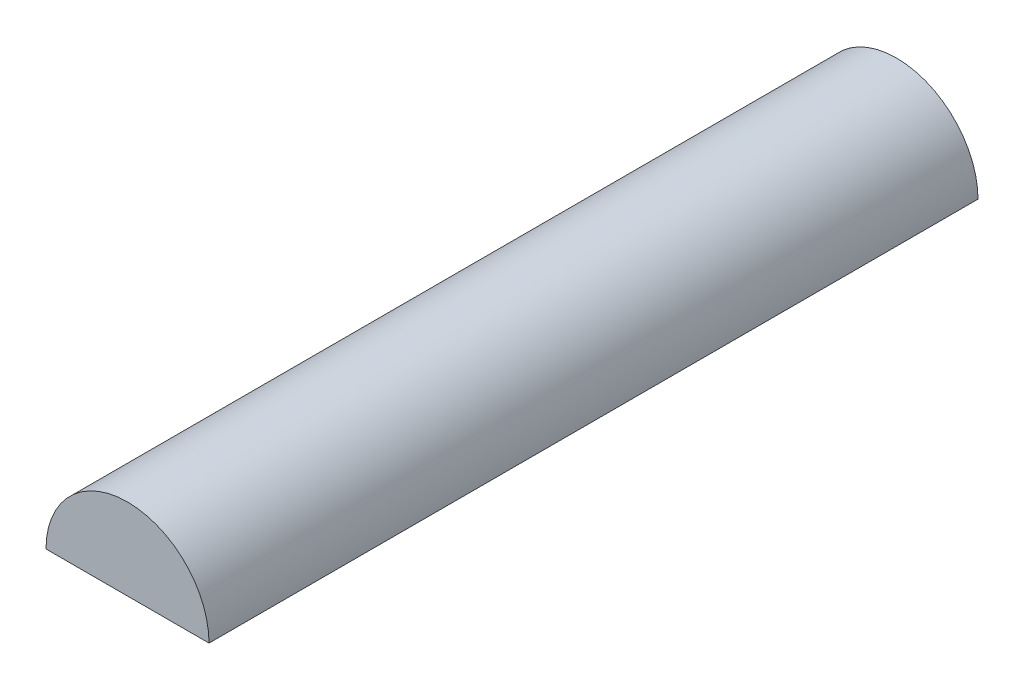
from build123d import *

# Parameters (mm, degrees)
BOSS_EXTRUDE1_DEPTH = 25


with BuildPart() as part:
    # Sketch1 → Boss-Extrude1 (new body)
    with BuildSketch(Plane.XY):
        with BuildLine():
            Line((-2.65, 0), (2.65, 0))
            ThreePointArc((2.65, 0), (0, 2.65), (-2.65, 0))
        make_face()
    extrude(amount=BOSS_EXTRUDE1_DEPTH)


solid = part.part
